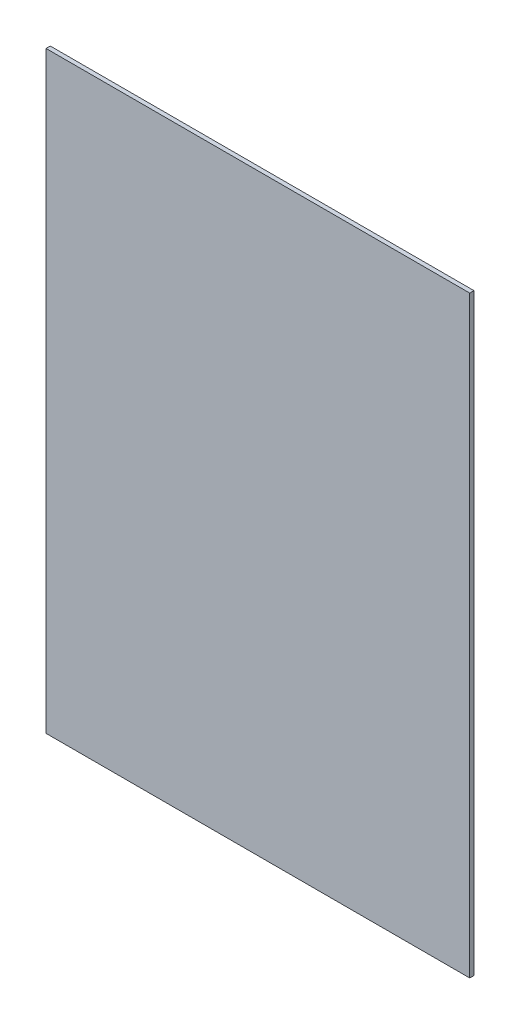
from build123d import *

# Parameters (mm, degrees)
CROQUIS1_W              = 500
CROQUIS1_H              = 700
SALIENTE_EXTRUIR1_DEPTH = 5


with BuildPart() as part:
    # Croquis1 → Saliente-Extruir1 (new body)
    with BuildSketch(Plane.XY):
        with Locations((287.989868277, 385.90247191)):
            Rectangle(CROQUIS1_W, CROQUIS1_H)
    extrude(amount=SALIENTE_EXTRUIR1_DEPTH)


solid = part.part
